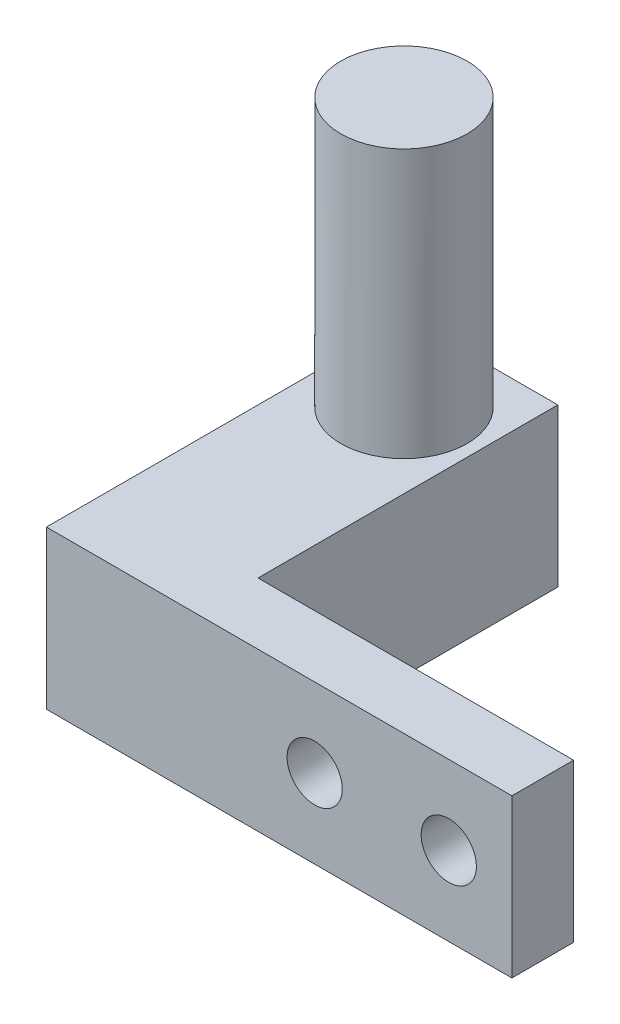
from build123d import *

# Parameters (mm, degrees)
SKETCH1_W           = 12.5
SKETCH1_H           = 10
BOSS_EXTRUDE1_DEPTH = 10
SKETCH2_W           = 10
SKETCH2_H           = 10
BOSS_EXTRUDE2_DEPTH = 5
SKETCH3_R           = 4
BOSS_EXTRUDE3_DEPTH = 17
SKETCH4_W           = 4
SKETCH4_H           = 10
CUT_EXTRUDE1_DEPTH  = 11
SKETCH5_W           = 9.5
SKETCH5_H           = 10
BOSS_EXTRUDE4_DEPTH = 12.5
SKETCH6_W           = 5
SKETCH6_H           = 10
BOSS_EXTRUDE5_DEPTH = 30
SKETCH7_R           = 1.75
CUT_EXTRUDE2_DEPTH  = 23.5
SKETCH8_W           = 30
SKETCH8_H           = 5
CUT_EXTRUDE4_DEPTH  = 10
SKETCH10_W          = 9.5
SKETCH10_H          = 10
CUT_EXTRUDE6_DEPTH  = 3.49
SKETCH11_W          = 9.5
SKETCH11_H          = 10
BOSS_EXTRUDE6_DEPTH = 3.9
SKETCH12_W          = 4
SKETCH12_H          = 10
BOSS_EXTRUDE7_DEPTH = 20
SKETCH13_W          = 20
SKETCH13_H          = 0.09
CUT_EXTRUDE7_DEPTH  = 28
SKETCH14_R          = 1.75
CUT_EXTRUDE8_DEPTH  = 23.91


with BuildPart() as part:
    # Sketch1 → Boss-Extrude1 (new body)
    with BuildSketch(Plane.XY):
        with Locations((6.25, 5)):
            Rectangle(SKETCH1_W, SKETCH1_H)
    extrude(amount=BOSS_EXTRUDE1_DEPTH)

    # Sketch2 → Boss-Extrude2 (add)
    with BuildSketch(Plane.ZY):
        with Locations((5, 5)):
            Rectangle(SKETCH2_W, SKETCH2_H)
    extrude(amount=BOSS_EXTRUDE2_DEPTH)

    # Sketch3 → Boss-Extrude3 (add)
    with BuildSketch(Plane(origin=(0, 10, 0), x_dir=(1, 0, 0), z_dir=(0, 1, 0))):
        with Locations((3.75, -5)):
            Circle(SKETCH3_R)
    extrude(amount=BOSS_EXTRUDE3_DEPTH)

    # Sketch4 → Cut-Extrude1 (cut, through all)
    with BuildSketch(Plane(origin=(0, 10, 0), x_dir=(1, 0, 0), z_dir=(0, 1, 0))):
        with Locations((10.5, -5)):
            Rectangle(SKETCH4_W, SKETCH4_H)
        with Locations((-3, -5)):
            Rectangle(SKETCH4_W, SKETCH4_H)
    extrude(amount=-CUT_EXTRUDE1_DEPTH, mode=Mode.SUBTRACT)

    # Sketch5 → Boss-Extrude4 (add)
    with BuildSketch(Plane.XY.offset(10)):
        with Locations((3.75, 5)):
            Rectangle(SKETCH5_W, SKETCH5_H)
    extrude(amount=BOSS_EXTRUDE4_DEPTH)

    # Sketch6 → Boss-Extrude5 (add)
    with BuildSketch(Plane(origin=(8.5, 0, 0), x_dir=(0, 0, -1), z_dir=(1, 0, 0))):
        with Locations((-20, 5)):
            Rectangle(SKETCH6_W, SKETCH6_H)
    extrude(amount=BOSS_EXTRUDE5_DEPTH)

    # Sketch7 → Cut-Extrude2 (cut, through all)
    with BuildSketch(Plane.XY.offset(22.5)):
        with Locations((22.5, 5)):
            Circle(SKETCH7_R)
        with Locations((33.5, 5)):
            Circle(SKETCH7_R)
    extrude(amount=-CUT_EXTRUDE2_DEPTH, mode=Mode.SUBTRACT)

    # Sketch8 → Cut-Extrude4 (cut)
    with BuildSketch(Plane(origin=(0, 10, 0), x_dir=(1, 0, 0), z_dir=(0, 1, 0))):
        with Locations((23.5, -20)):
            Rectangle(SKETCH8_W, SKETCH8_H)
    extrude(amount=-CUT_EXTRUDE4_DEPTH, mode=Mode.SUBTRACT)

    # Sketch10 → Cut-Extrude6 (cut)
    with BuildSketch(Plane.XY.offset(22.5)):
        with Locations((3.75, 5)):
            Rectangle(SKETCH10_W, SKETCH10_H)
    extrude(amount=-CUT_EXTRUDE6_DEPTH, mode=Mode.SUBTRACT)

    # Sketch11 → Boss-Extrude6 (add)
    with BuildSketch(Plane.XY.offset(19.01)):
        with Locations((3.75, 5)):
            Rectangle(SKETCH11_W, SKETCH11_H)
    extrude(amount=BOSS_EXTRUDE6_DEPTH)

    # Sketch12 → Boss-Extrude7 (add)
    with BuildSketch(Plane(origin=(8.5, 0, 0), x_dir=(0, 0, -1), z_dir=(1, 0, 0))):
        with Locations((-20.91, 5)):
            Rectangle(SKETCH12_W, SKETCH12_H)
    extrude(amount=BOSS_EXTRUDE7_DEPTH)

    # Sketch13 → Cut-Extrude7 (cut, through all)
    with BuildSketch(Plane(origin=(0, 0, 0), x_dir=(-1, 0, 0), z_dir=(0, -1, 0))):
        with Locations((-18.5, -18.955)):
            Rectangle(SKETCH13_W, SKETCH13_H)
    extrude(amount=-CUT_EXTRUDE7_DEPTH, mode=Mode.SUBTRACT)

    # Sketch14 → Cut-Extrude8 (cut, through all)
    with BuildSketch(Plane.XY.offset(22.91)):
        with Locations((16, 5)):
            Circle(SKETCH14_R)
        with Locations((24.5, 5)):
            Circle(SKETCH14_R)
    extrude(amount=-CUT_EXTRUDE8_DEPTH, mode=Mode.SUBTRACT)


solid = part.part
